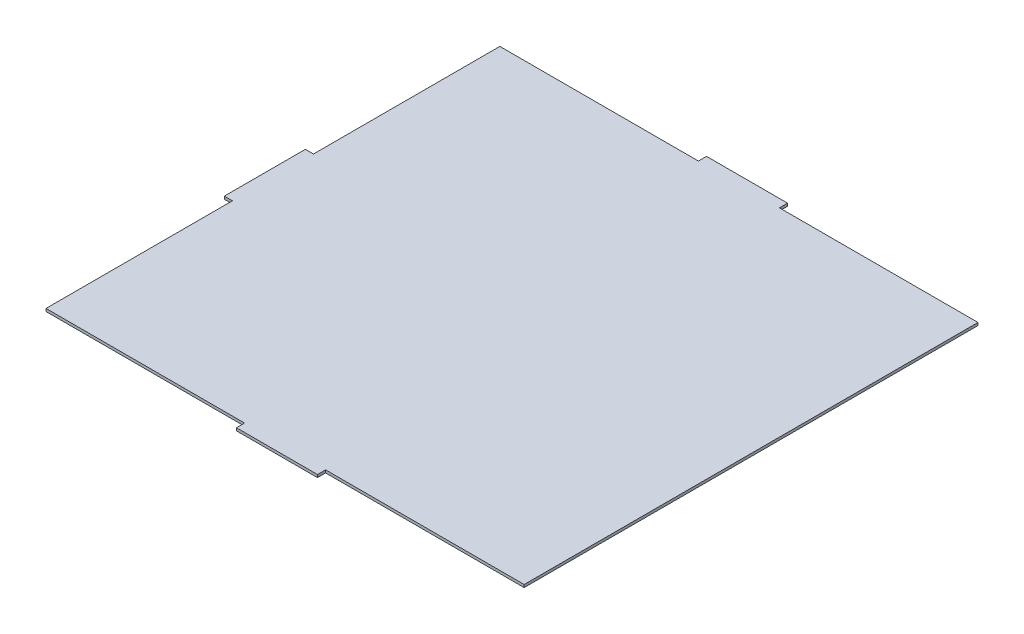
from build123d import *

# Parameters (mm, degrees)
BOSS_EXTRUDE1_DEPTH = 1


with BuildPart() as part:
    # Sketch1 → Boss-Extrude1 (new body)
    with BuildSketch(Plane(origin=(0, 0, 0), x_dir=(1, 0, 0), z_dir=(0, 1, 0))):
        Polygon((-51.678024066, 119.99196612), (21.821975934, 119.99196612), (21.821975934, 122.99196612), (51.821975934, 122.99196612), (51.821975934, 119.99196612), (125.321975934, 119.99196612), (125.321975934, -48.00803388), (51.821975934, -48.00803388), (51.821975934, -51.00803388), (21.821975934, -51.00803388), (21.821975934, -48.00803388), (-51.678024066, -48.00803388), (-51.678024066, 20.99196612), (-54.678024066, 20.99196612), (-54.678024066, 50.99196612), (-51.678024066, 50.99196612), align=None)
    extrude(amount=BOSS_EXTRUDE1_DEPTH)


solid = part.part
